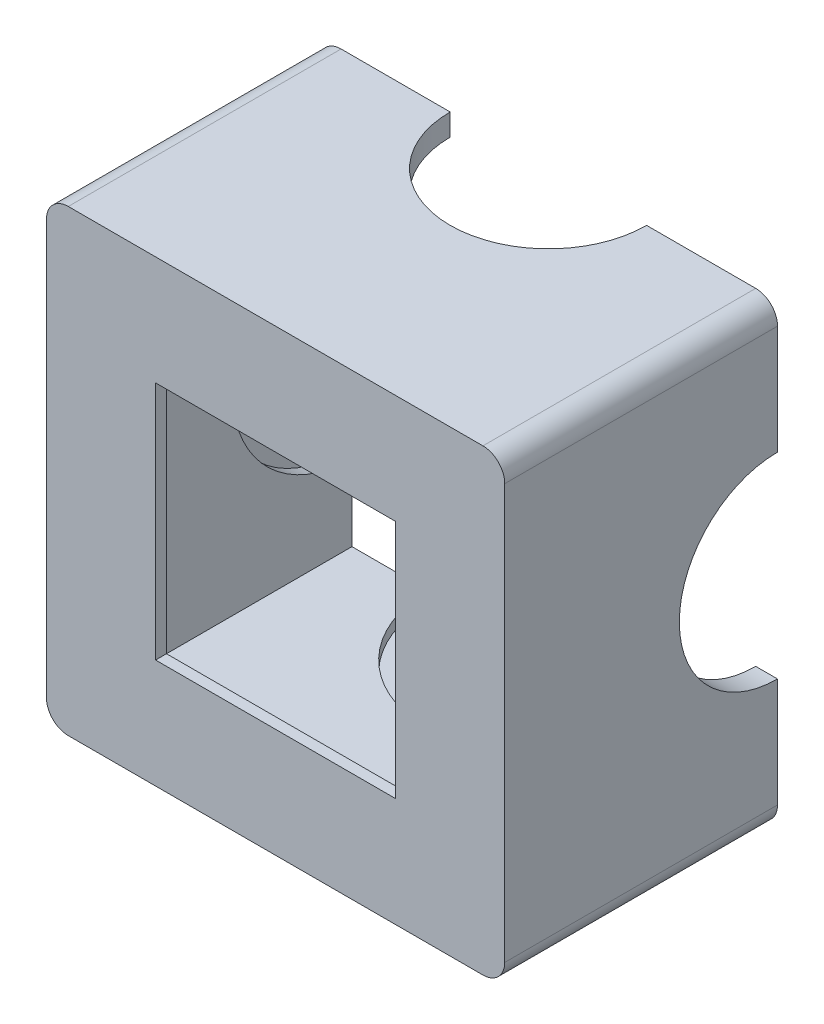
from build123d import *

# Parameters (mm, degrees)
SKETCH1_W           = 42
SKETCH1_H           = 42
SKETCH1_W_2         = 36
SKETCH1_H_2         = 36
BOSS_EXTRUDE1_DEPTH = 24
SKETCH3_R           = 11
CUT_EXTRUDE1_DEPTH  = 1
SKETCH5_R           = 9
CUT_EXTRUDE2_DEPTH  = 4
SKETCH14_W          = 42
SKETCH14_H          = 42
BOSS_EXTRUDE3_DEPTH = 1
CIRPATTERN1_COUNT   = 4
FILLET1_R           = 2
SKETCH15_W          = 22
SKETCH15_H          = 22
CUT_EXTRUDE3_DEPTH  = 26


with BuildPart() as part:
    # Sketch1 → Boss-Extrude1 (new body)
    with BuildSketch(Plane.XY):
        Rectangle(SKETCH1_W, SKETCH1_H)
        Rectangle(SKETCH1_W_2, SKETCH1_H_2, mode=Mode.SUBTRACT)
    extrude(amount=BOSS_EXTRUDE1_DEPTH)

    # Sketch3 → Cut-Extrude1 (cut)
    with BuildSketch(Plane.ZY.offset(-18)):
        Circle(SKETCH3_R)
    cut_extrude1 = extrude(amount=-CUT_EXTRUDE1_DEPTH, mode=Mode.SUBTRACT)

    # Sketch5 → Cut-Extrude2 (cut, through all)
    with BuildSketch(Plane.ZY.offset(-18)):
        Circle(SKETCH5_R)
    cut_extrude2 = extrude(amount=-CUT_EXTRUDE2_DEPTH, mode=Mode.SUBTRACT)

    # Sketch14 → Boss-Extrude3 (add)
    with BuildSketch(Plane.XY.offset(24)):
        Rectangle(SKETCH14_W, SKETCH14_H)
    extrude(amount=BOSS_EXTRUDE3_DEPTH)

    # CirPattern1: Cut-Extrude1, Cut-Extrude2 ×4 about axis
    cirpattern1_axis = Axis((0, 0, 0), (0, 0, 1))
    for i in range(1, CIRPATTERN1_COUNT):
        add(cut_extrude1.rotate(cirpattern1_axis, i * 360 / CIRPATTERN1_COUNT), mode=Mode.SUBTRACT)
        add(cut_extrude2.rotate(cirpattern1_axis, i * 360 / CIRPATTERN1_COUNT), mode=Mode.SUBTRACT)

    # Fillet1
    fillet1_edges = [part.edges().sort_by_distance(p)[0] for p in [
        (21, -21, 12.5),
        (-21, -21, 12.5),
        (-21, 21, 12.5),
        (21, 21, 12.5),
    ]]
    fillet(fillet1_edges, radius=FILLET1_R)

    # Sketch15 → Cut-Extrude3 (cut, through all)
    with BuildSketch(Plane.XY.offset(25)):
        Rectangle(SKETCH15_W, SKETCH15_H)
    extrude(amount=-CUT_EXTRUDE3_DEPTH, mode=Mode.SUBTRACT)


solid = part.part
